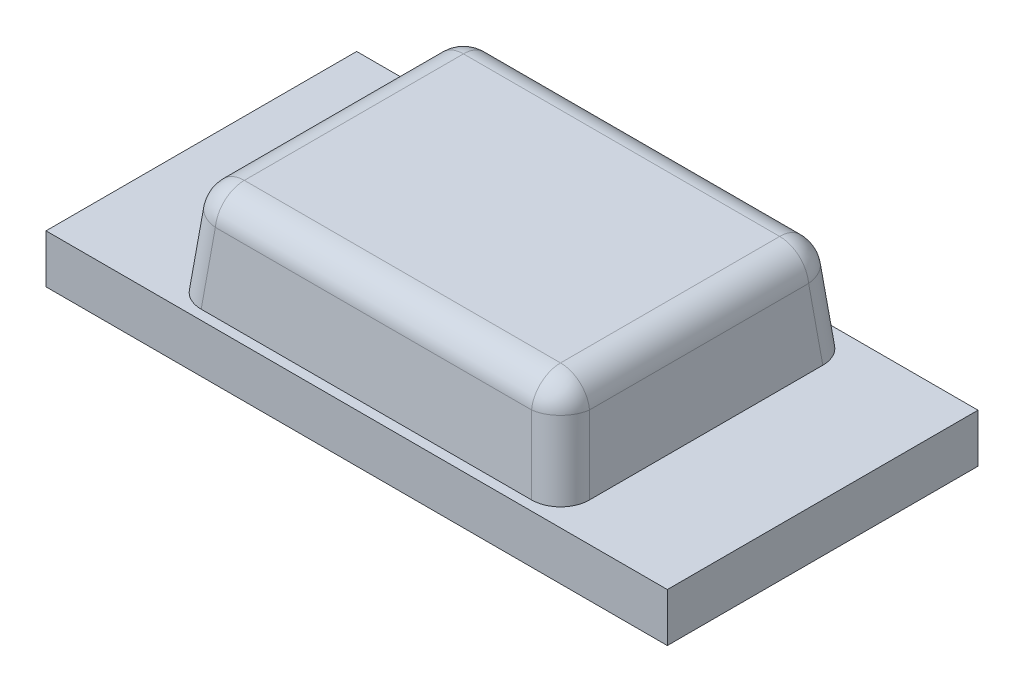
from build123d import *

# Parameters (mm, degrees)
SKETCH2_W           = 3.2
SKETCH2_H           = 1.6
BOSS_EXTRUDE1_DEPTH = 0.25
SKETCH4_W           = 2
SKETCH4_H           = 1.5
BOSS_EXTRUDE2_DEPTH = 0.5
BOSS_EXTRUDE2_TAPER = 5.71
FILLET1_R           = 0.15


with BuildPart() as part:
    # Sketch2 → Boss-Extrude1 (new body)
    with BuildSketch(Plane(origin=(0, 0, 0), x_dir=(1, 0, 0), z_dir=(0, 1, 0))):
        Rectangle(SKETCH2_W, SKETCH2_H)
    extrude(amount=BOSS_EXTRUDE1_DEPTH)

    # Sketch4 → Boss-Extrude2 (add)
    with BuildSketch(Plane(origin=(0, 0.25, 0), x_dir=(1, 0, 0), z_dir=(0, 1, 0))):
        Rectangle(SKETCH4_W, SKETCH4_H)
    extrude(amount=BOSS_EXTRUDE2_DEPTH, taper=BOSS_EXTRUDE2_TAPER)

    # Fillet1
    fillet1_edges = [part.edges().sort_by_distance(p)[0] for p in [
        (0.975002614, 0.5, 0.725002614),
        (0.975002614, 0.5, -0.725002614),
        (-0.975002614, 0.5, -0.725002614),
        (-0.975002614, 0.5, 0.725002614),
        (0.950005228, 0.75, 0),
        (0, 0.75, -0.700005228),
        (-0.950005228, 0.75, 0),
        (0, 0.75, 0.700005228),
    ]]
    fillet(fillet1_edges, radius=FILLET1_R)


solid = part.part
